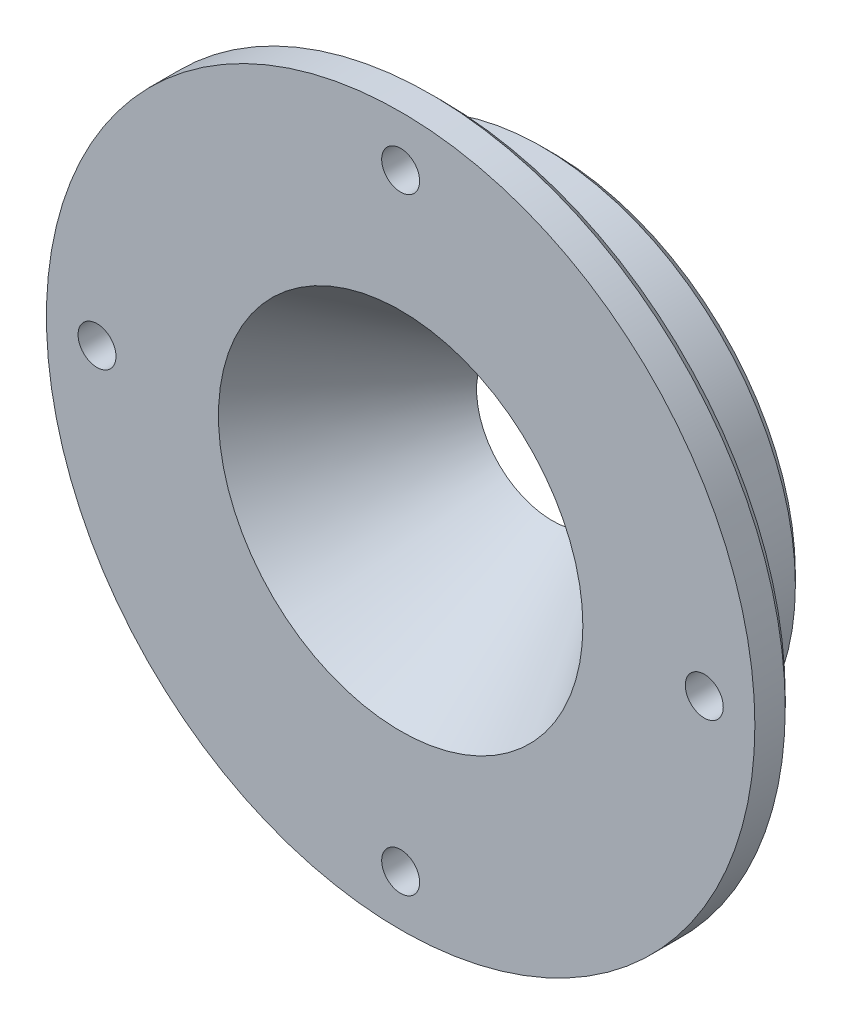
from build123d import *

# Parameters (mm, degrees)
F_3_16_0_1875_DIAMETER_HOLE1_D = 4.7625
FILLET1_R                      = 2.54
CHAMFER1_SIZE                  = 1.27


with BuildPart() as part:
    # Sketch1 → Revolve1 (revolve)
    with BuildSketch(Plane(origin=(0, 0, 0), x_dir=(0, 0, -1), z_dir=(1, 0, 0))):
        Polygon((0, 22.863953603), (19.05, 9.525), (19.05, 31.75), (5.08, 31.75), (5.08, 44.45), (0, 44.45), align=None)
    revolve(axis=Axis((0, 0, 18.454150881), (0, 0, -1)))

    # 3/16 (0.1875) Diameter Hole1 (through all)
    with Locations(Plane.XY):
        with Locations((0, 38.1), (38.1, 0), (0, -38.1), (-38.1, 0), (0, 0)):
            Hole(F_3_16_0_1875_DIAMETER_HOLE1_D / 2)

    # Fillet1
    fillet1_edges = [part.edges().sort_by_distance(p)[0] for p in [
        (0, -31.75, -5.08),
    ]]
    fillet(fillet1_edges, radius=FILLET1_R)

    # Chamfer1
    chamfer1_edges = [part.edges().sort_by_distance(p)[0] for p in [
        (0, -31.75, -19.05),
        (0, -44.45, -5.08),
    ]]
    chamfer(chamfer1_edges, length=CHAMFER1_SIZE)


solid = part.part
